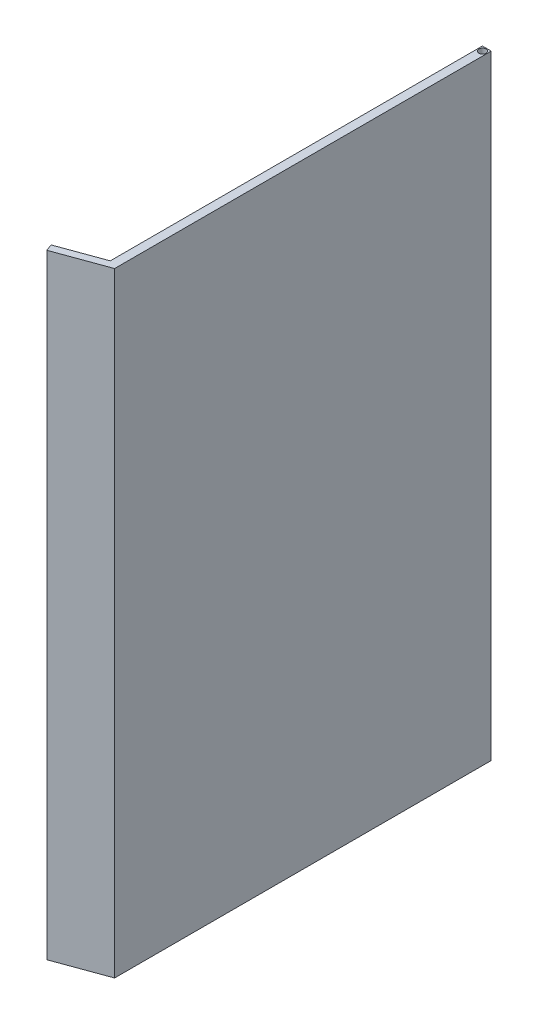
from build123d import *

# Parameters (mm, degrees)
BOSS_EXTRUDE1_DEPTH = 85
SKETCH6_R           = 0.501484151
CUT_EXTRUDE1_DEPTH  = 94.234565894
SKETCH7_R           = 0.300235793
BOSS_EXTRUDE2_DEPTH = 0.5
LPATTERN1_COUNT     = 9
LPATTERN1_PITCH     = 10


with BuildPart() as part:
    # Sketch5 → Boss-Extrude1 (new body)
    with BuildSketch(Plane(origin=(0, 0, 0), x_dir=(1, 0, 0), z_dir=(0, 1, 0))):
        Polygon((0, 16.765910013), (0, -34.714089987), (-6, -36.897911392), (-5.657979857, -37.837604013), (1.219310648, -35.334474977), (1.219310648, 16.765910013), align=None)
    extrude(amount=BOSS_EXTRUDE1_DEPTH)

    # Sketch6 → Cut-Extrude1 (cut, through all)
    with BuildSketch(Plane(origin=(0, 85, 0), x_dir=(1, 0, 0), z_dir=(0, 1, 0))):
        with Locations((0.617040076, 16.161484854)):
            Circle(SKETCH6_R)
    extrude(amount=-CUT_EXTRUDE1_DEPTH, mode=Mode.SUBTRACT)

    # Sketch7 → Boss-Extrude2 (add)
    with BuildSketch(Plane(origin=(11.156893463, 0, 30.65331286), x_dir=(-0.9396926207859091, 0, 0.3420201433256667), z_dir=(-0.34202014332566677, 0, -0.9396926207859092))):
        with Locations((16.976051075, 83.790382872)):
            Circle(SKETCH7_R)
    boss_extrude2 = extrude(amount=BOSS_EXTRUDE2_DEPTH)

    # Sketch10 → Revolve1 (revolve)
    with BuildSketch(Plane(origin=(-13.67960191, -0.418101739, 4.978967912), x_dir=(0.34171959685752173, 0.010444277455924904, 0.9397439194759158), z_dir=(-0.939305295450006, -0.02870881626841483, 0.3418791684324207))):
        Polygon((33.002180094, 84.203214447), (33.002180094, 83.902962264), (32.435969012, 83.908878691), align=None)
    revolve1 = revolve(axis=Axis((-4.965313546, 83.790382872, 35.992565984), (-0.34202014332567104, 0, -0.9396926207859075)))

    # LPattern1: Boss-Extrude2, Revolve1 ×9
    with Locations(*[(0, -i * LPATTERN1_PITCH, 0) for i in range(1, LPATTERN1_COUNT)]):
        add(boss_extrude2)
        add(revolve1)


solid = part.part
